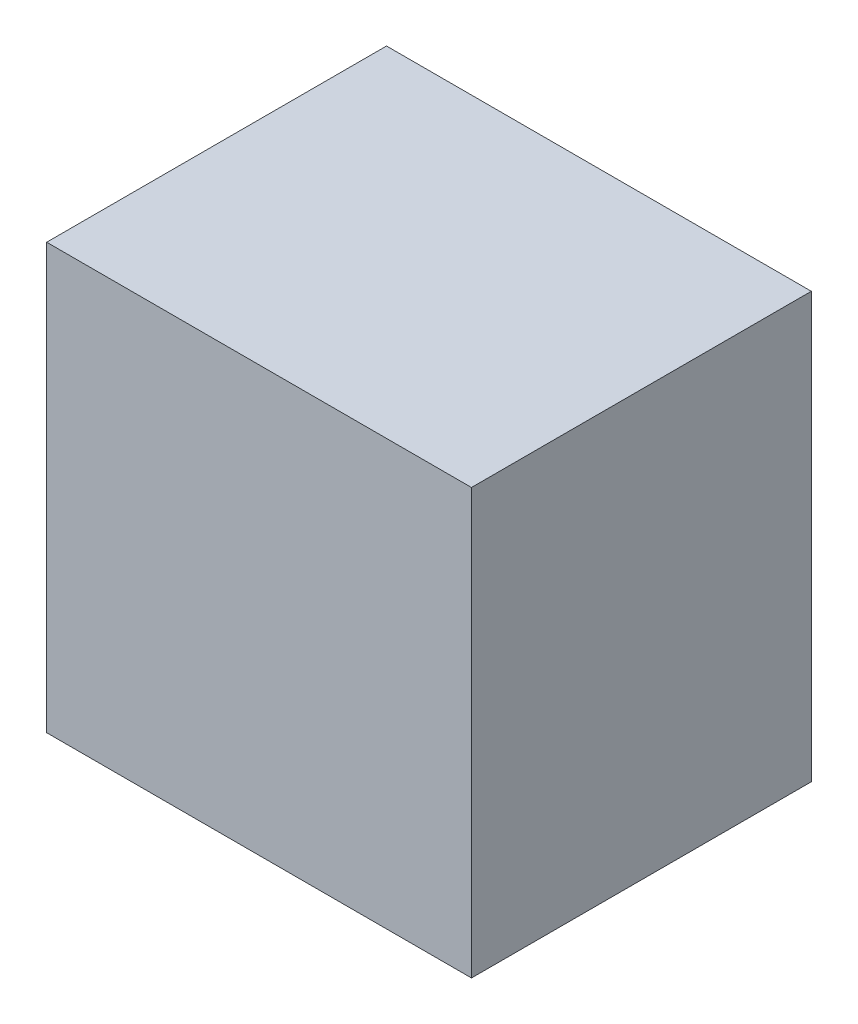
from build123d import *

# Parameters (mm, degrees)
SKETCH1_W           = 25
SKETCH1_H           = 25
BOSS_EXTRUDE1_DEPTH = 20


with BuildPart() as part:
    # Sketch1 → Boss-Extrude1 (new body)
    with BuildSketch(Plane.XY):
        with Locations((12.5, 12.5)):
            Rectangle(SKETCH1_W, SKETCH1_H)
    extrude(amount=BOSS_EXTRUDE1_DEPTH)


solid = part.part
